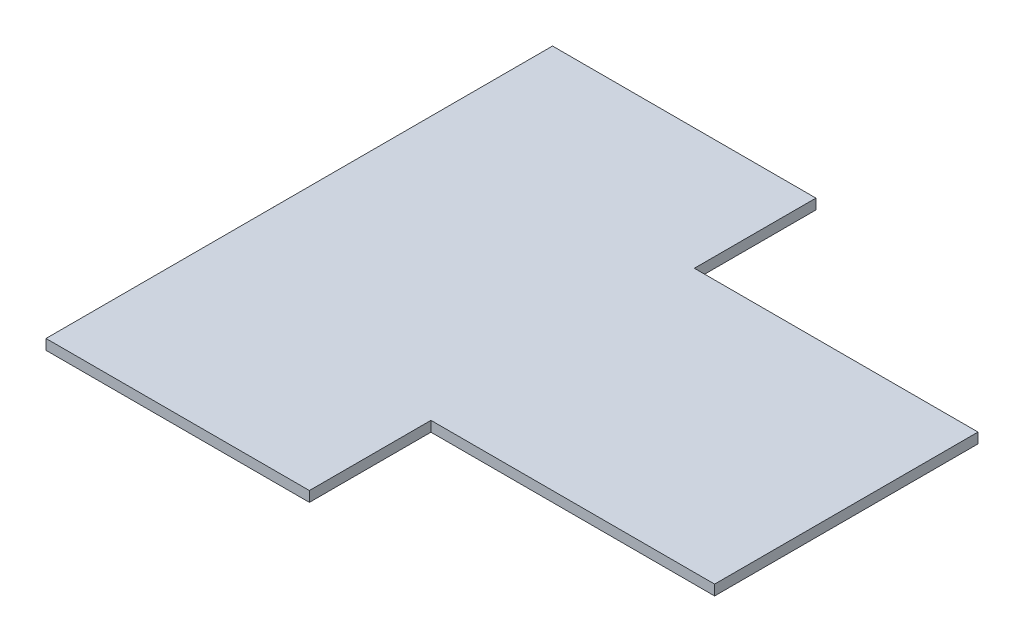
from build123d import *

# Parameters (mm, degrees)
BOSS_EXTRUDE1_DEPTH = 1.27


with BuildPart() as part:
    # Sketch1 → Boss-Extrude1 (new body, symmetric)
    with BuildSketch(Plane(origin=(0, 0, 0), x_dir=(1, 0, 0), z_dir=(0, 1, 0))):
        Polygon((67.5, -32.5), (67.5, 32.5), (-2.5, 32.5), (-2.5, 62.5), (-67.5, 62.5), (-67.5, -62.5), (-2.5, -62.5), (-2.5, -32.5), align=None)
    extrude(amount=BOSS_EXTRUDE1_DEPTH, both=True)


solid = part.part
